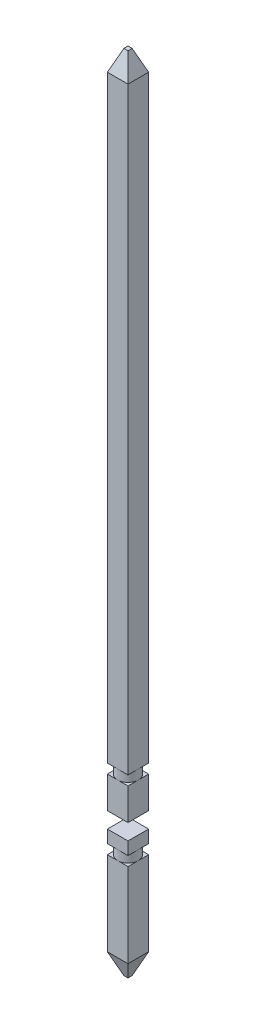
from build123d import *

# Parameters (mm, degrees)
SKETCH2_W             = 0.65
SKETCH2_H             = 0.65
BOSS_EXTRUDE1_DEPTH   = 25.3
SKETCH6_W             = 0.65
SKETCH6_H             = 0.5
CUT_EXTRUDE1_DEPTH    = 1.65
SKETCH7_W             = 0.65
SKETCH7_H             = 0.3
CUT_EXTRUDE2_DEPTH    = 1.65
SKETCH8_R             = 0.325
BOSS_EXTRUDE2_DEPTH   = 0.3
SKETCH9_W             = 0.65
SKETCH9_H             = 0.3
CUT_EXTRUDE3_DEPTH    = 1.65
SKETCH10_R            = 0.325
BOSS_EXTRUDE3_DEPTH   = 0.3
CHAMFER1_SIZE         = 0.65
CHAMFER1_SIZE2        = 0.26
CHAMFER1_PART_2_SIZE  = 0.65
CHAMFER1_PART_2_SIZE2 = 0.26
CHAMFER1_PART_3_SIZE  = 0.65
CHAMFER1_PART_3_SIZE2 = 0.26
CHAMFER1_PART_4_SIZE  = 0.65
CHAMFER1_PART_4_SIZE2 = 0.26
CHAMFER2_SIZE         = 0.26
CHAMFER2_SIZE2        = 0.65


with BuildPart() as part:
    # Sketch2 → Boss-Extrude1 (new body)
    with BuildSketch(Plane(origin=(0, 0, 0), x_dir=(1, 0, 0), z_dir=(0, 1, 0))):
        Rectangle(SKETCH2_W, SKETCH2_H)
    extrude(amount=BOSS_EXTRUDE1_DEPTH)

    # Sketch6 → Cut-Extrude1 (cut, through all)
    with BuildSketch(Plane.XY.offset(0.325)):
        with Locations((0, 4.25)):
            Rectangle(SKETCH6_W, SKETCH6_H)
    extrude(amount=-CUT_EXTRUDE1_DEPTH, mode=Mode.SUBTRACT)

    # Sketch7 → Cut-Extrude2 (cut, through all)
    with BuildSketch(Plane.XY.offset(0.325)):
        with Locations((0, 3.45)):
            Rectangle(SKETCH7_W, SKETCH7_H)
    extrude(amount=-CUT_EXTRUDE2_DEPTH, mode=Mode.SUBTRACT)

    # Sketch8 → Boss-Extrude2 (add)
    with BuildSketch(Plane(origin=(0, 3.3, 0), x_dir=(1, 0, 0), z_dir=(0, 1, 0))):
        Circle(SKETCH8_R)
    extrude(amount=BOSS_EXTRUDE2_DEPTH)

    # Sketch9 → Cut-Extrude3 (cut, through all)
    with BuildSketch(Plane.XY.offset(0.325)):
        with Locations((0, 5.65)):
            Rectangle(SKETCH9_W, SKETCH9_H)
    extrude(amount=-CUT_EXTRUDE3_DEPTH, mode=Mode.SUBTRACT)

    # Sketch10 → Boss-Extrude3 (add)
    with BuildSketch(Plane(origin=(0, 5.5, 0), x_dir=(1, 0, 0), z_dir=(0, 1, 0))):
        Circle(SKETCH10_R)
    extrude(amount=BOSS_EXTRUDE3_DEPTH)

    # Chamfer1
    chamfer1_edges = [part.edges().sort_by_distance(p)[0] for p in [
        (0.325, 25.3, 0),
    ]]
    chamfer1_side = [part.faces().sort_by_distance(p)[0] for p in [
        (0.325, 15.55, 0),
    ]]
    chamfer(chamfer1_edges, length=CHAMFER1_SIZE, length2=CHAMFER1_SIZE2, reference=chamfer1_side[0])

    # Chamfer1 part 2
    chamfer1_part_2_edges = [part.edges().sort_by_distance(p)[0] for p in [
        (0, 25.3, -0.325),
    ]]
    chamfer1_part_2_side = [part.faces().sort_by_distance(p)[0] for p in [
        (0, 15.55, -0.325),
    ]]
    chamfer(chamfer1_part_2_edges, length=CHAMFER1_PART_2_SIZE, length2=CHAMFER1_PART_2_SIZE2, reference=chamfer1_part_2_side[0])

    # Chamfer1 part 3
    chamfer1_part_3_edges = [part.edges().sort_by_distance(p)[0] for p in [
        (-0.325, 25.3, 0),
    ]]
    chamfer1_part_3_side = [part.faces().sort_by_distance(p)[0] for p in [
        (-0.325, 15.55, 0),
    ]]
    chamfer(chamfer1_part_3_edges, length=CHAMFER1_PART_3_SIZE, length2=CHAMFER1_PART_3_SIZE2, reference=chamfer1_part_3_side[0])

    # Chamfer1 part 4
    chamfer1_part_4_edges = [part.edges().sort_by_distance(p)[0] for p in [
        (0, 25.3, 0.325),
    ]]
    chamfer1_part_4_side = [part.faces().sort_by_distance(p)[0] for p in [
        (0, 15.55, 0.325),
    ]]
    chamfer(chamfer1_part_4_edges, length=CHAMFER1_PART_4_SIZE, length2=CHAMFER1_PART_4_SIZE2, reference=chamfer1_part_4_side[0])

    # Chamfer2
    chamfer2_edges = [part.edges().sort_by_distance(p)[0] for p in [
        (0, 0, 0.325),
        (-0.325, 0, 0),
        (0, 0, -0.325),
        (0.325, 0, 0),
    ]]
    chamfer2_side = [part.faces().sort_by_distance(p)[0] for p in [
        (0, 0, 0),
    ]]
    chamfer(chamfer2_edges, length=CHAMFER2_SIZE, length2=CHAMFER2_SIZE2, reference=chamfer2_side[0])


solid = part.part
